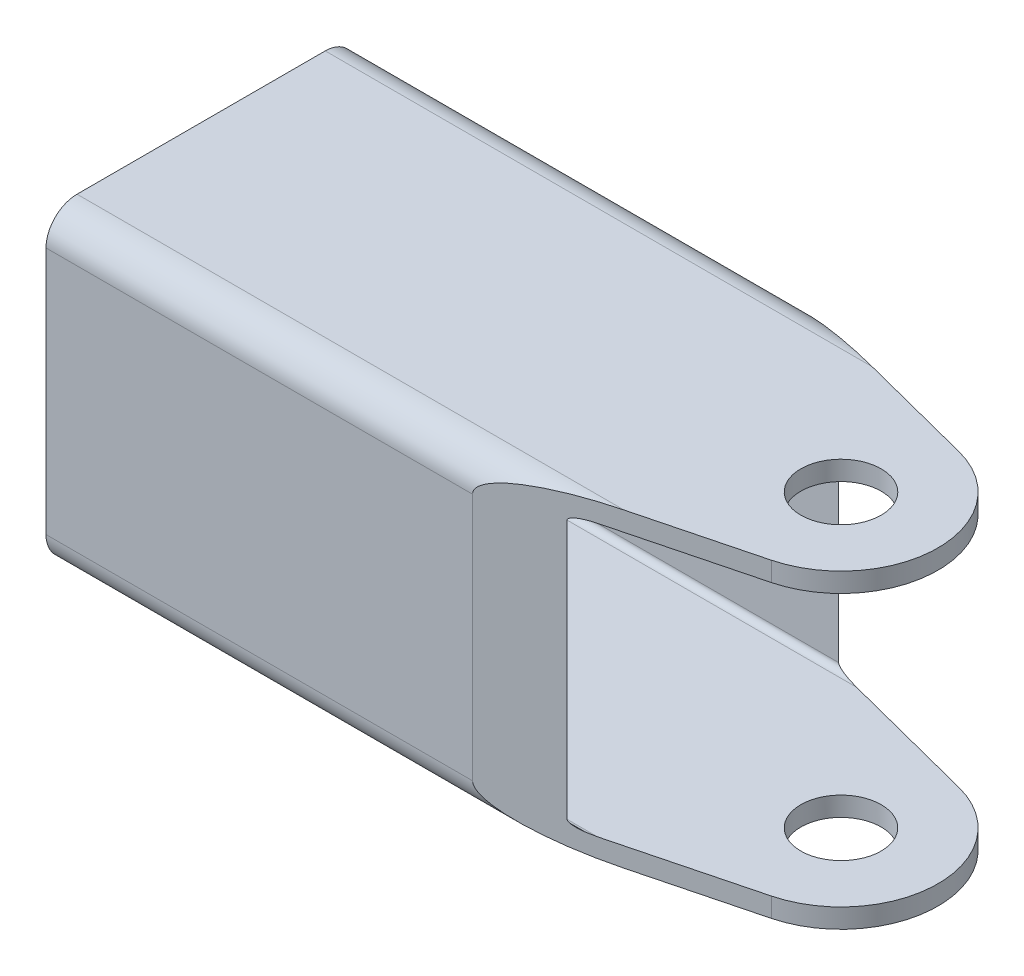
from build123d import *

# Parameters (mm, degrees)
BOSS_EXTRUDE1_DEPTH      = 25.4
BOSS_EXTRUDE1_DEPTH_BACK = 34.925
CUT_EXTRUDE4_DEPTH       = 61.325
CUT_EXTRUDE5_DEPTH       = 26.4
SKETCH14_R               = 3.2893
CUT_EXTRUDE6_DEPTH       = 26.4


with BuildPart() as part:
    # Sketch1 → Boss-Extrude1 (new body, two sides)
    with BuildSketch(Plane(origin=(0, 0, 0), x_dir=(0, 0, -1), z_dir=(1, 0, 0))) as boss_extrude1_sk:
        with BuildLine():
            Line((-10.16, 12.7), (10.16, 12.7))
            ThreePointArc((10.16, 12.7), (11.956051224, 11.956051224), (12.7, 10.16))
            Line((12.7, 10.16), (12.7, -10.16))
            ThreePointArc((12.7, -10.16), (11.956051224, -11.956051224), (10.16, -12.7))
            Line((10.16, -12.7), (-10.16, -12.7))
            ThreePointArc((-10.16, -12.7), (-11.956051224, -11.956051224), (-12.7, -10.16))
            Line((-12.7, -10.16), (-12.7, 10.16))
            ThreePointArc((-12.7, 10.16), (-11.956051224, 11.956051224), (-10.16, 12.7))
        make_face()
    extrude(amount=BOSS_EXTRUDE1_DEPTH)
    extrude(boss_extrude1_sk.sketch, amount=-BOSS_EXTRUDE1_DEPTH_BACK)

    # Sketch11 → Cut-Extrude4 (cut, through all)
    with BuildSketch(Plane(origin=(25.4, 0, 0), x_dir=(0, 0, -1), z_dir=(1, 0, 0))):
        with BuildLine():
            Line((-10.6045, 11.1125), (10.6045, 11.1125))
            ThreePointArc((10.6045, 11.1125), (10.963710245, 10.963710245), (11.1125, 10.6045))
            Line((11.1125, 10.6045), (11.1125, -10.6045))
            ThreePointArc((11.1125, -10.6045), (10.963710245, -10.963710245), (10.6045, -11.1125))
            Line((10.6045, -11.1125), (-10.6045, -11.1125))
            ThreePointArc((-10.6045, -11.1125), (-10.963710245, -10.963710245), (-11.1125, -10.6045))
            Line((-11.1125, -10.6045), (-11.1125, 10.6045))
            ThreePointArc((-11.1125, 10.6045), (-10.963710245, 10.963710245), (-10.6045, 11.1125))
        make_face()
    extrude(amount=-CUT_EXTRUDE4_DEPTH, mode=Mode.SUBTRACT)

    # Sketch12 → Cut-Extrude5 (cut, through all)
    with BuildSketch(Plane(origin=(0, 12.7, 0), x_dir=(1, 0, 0), z_dir=(0, 1, 0))):
        with BuildLine():
            Line((0, 12.7), (50.8, 12.7))
            Line((50.8, 12.7), (50.8, -12.7))
            Line((50.8, -12.7), (0, -12.7))
            Line((0, -12.7), (19.444424463, -7.686083637))
            ThreePointArc((19.444424463, -7.686083637), (25.4, 0), (19.444424463, 7.686083637))
            Line((19.444424463, 7.686083637), (0, 12.7))
        make_face()
    extrude(amount=-CUT_EXTRUDE5_DEPTH, mode=Mode.SUBTRACT)

    # Sketch14 → Cut-Extrude6 (cut, through all)
    with BuildSketch(Plane(origin=(0, 12.7, 0), x_dir=(1, 0, 0), z_dir=(0, 1, 0))):
        with Locations((17.4625, 0)):
            Circle(SKETCH14_R)
    extrude(amount=-CUT_EXTRUDE6_DEPTH, mode=Mode.SUBTRACT)


solid = part.part
